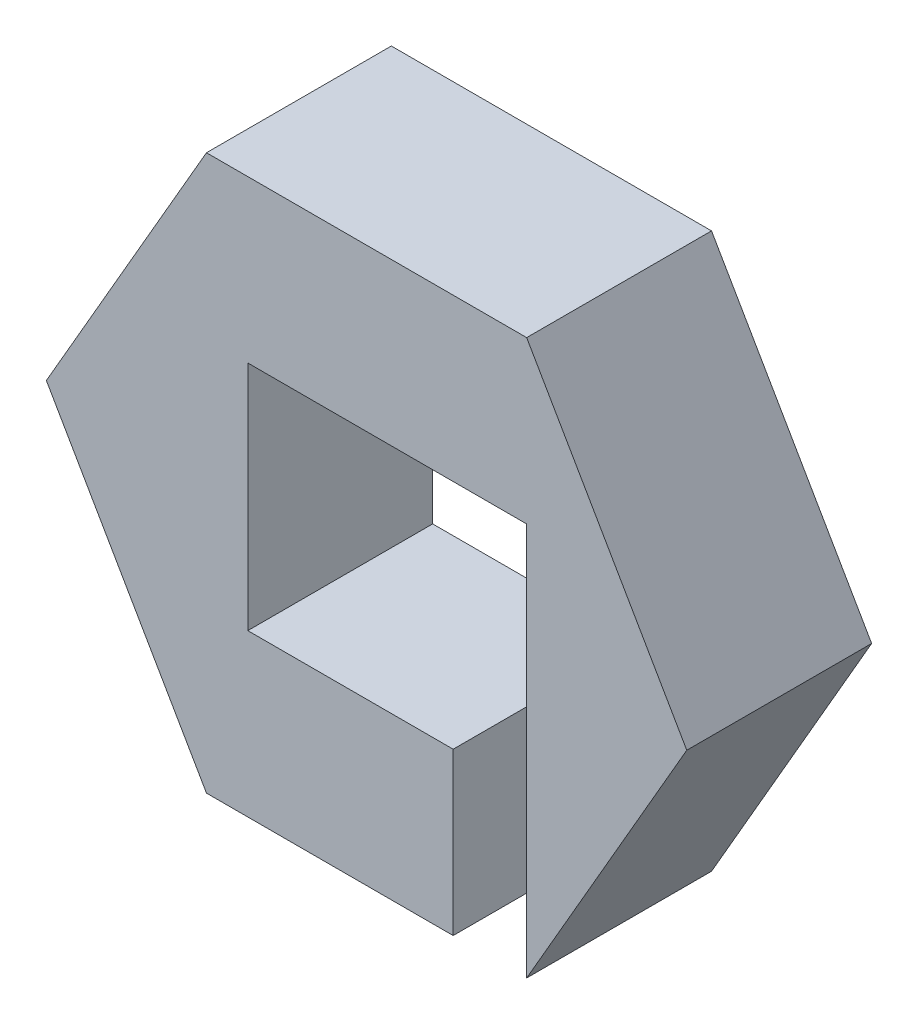
from build123d import *

# Parameters (mm, degrees)
BOSS_EXTRUDE1_DEPTH = 10
SKETCH2_W           = 12.8478013
SKETCH2_H           = 12.538959922
CUT_EXTRUDE1_DEPTH  = 11
CUT_EXTRUDE3_START  = -21.26948
SKETCH3_W           = 3.975573171
SKETCH3_H           = 10
CUT_EXTRUDE3_DEPTH  = 21.26948


with BuildPart() as part:
    # Sketch1 → Boss-Extrude1 (new body)
    with BuildSketch(Plane.XY):
        Polygon((17.320508076, 0), (8.660254038, 15), (-8.660254038, 15), (-17.320508076, 0), (-8.660254038, -15), (8.660254038, -15), align=None)
    extrude(amount=BOSS_EXTRUDE1_DEPTH)

    # Sketch2 → Cut-Extrude1 (cut, through all)
    with BuildSketch(Plane.XY.offset(10)):
        Rectangle(SKETCH2_W, SKETCH2_H)
    extrude(amount=-CUT_EXTRUDE1_DEPTH, mode=Mode.SUBTRACT)

    # Sketch3 → Cut-Extrude3 (cut)
    with BuildSketch(Plane.XZ.offset(15).offset(CUT_EXTRUDE3_START)):
        with Locations((6.672467452, 5)):
            Rectangle(SKETCH3_W, SKETCH3_H)
    extrude(amount=CUT_EXTRUDE3_DEPTH, mode=Mode.SUBTRACT)


solid = part.part
